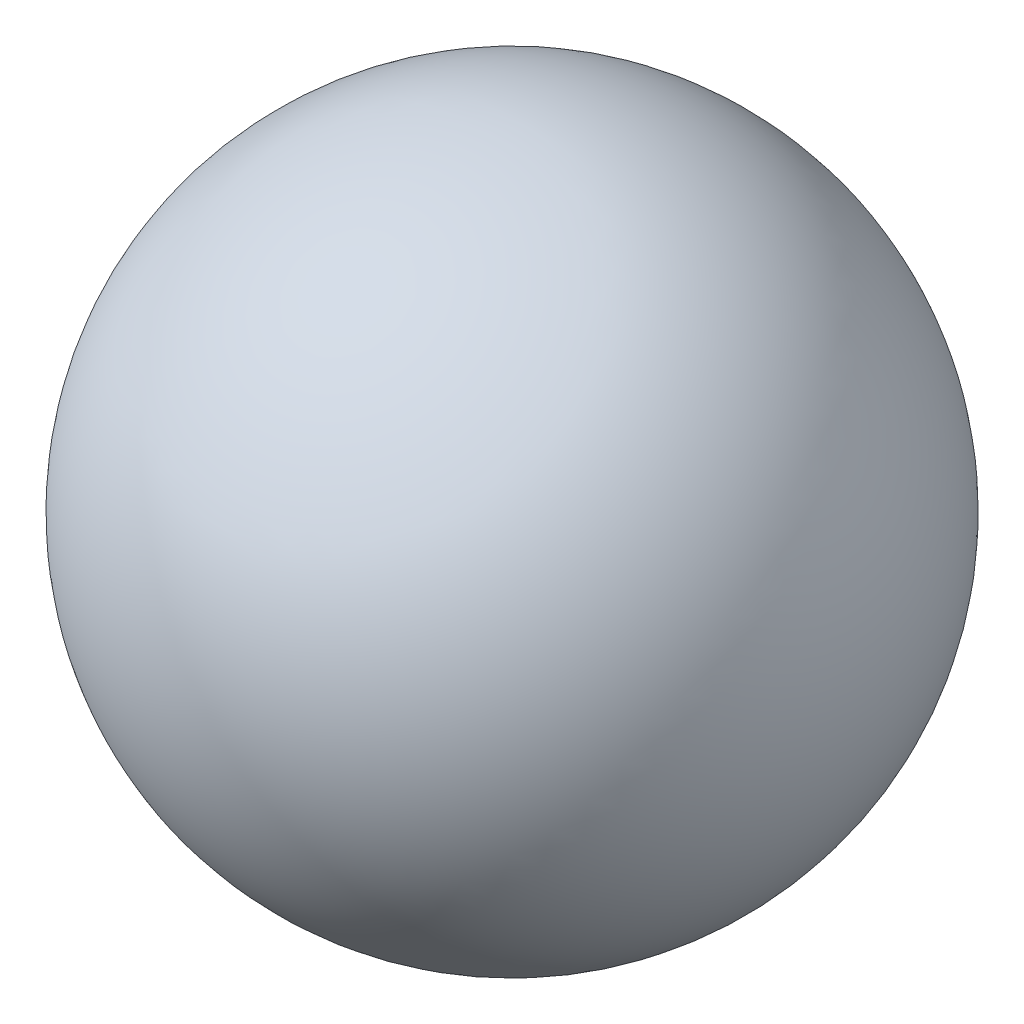
from build123d import *


with BuildPart() as part:
    # Sketch1 → Revolve1 (revolve)
    with BuildSketch(Plane(origin=(0, 0, 0), x_dir=(1, 0, 0), z_dir=(0, 1, 0))):
        with BuildLine():
            Line((0, 0), (0, 15))
            ThreePointArc((0, 15), (7.5, 7.5), (0, 0))
        make_face()
    revolve(axis=Axis((0, 0, 0), (0, 0, -1)))


solid = part.part
